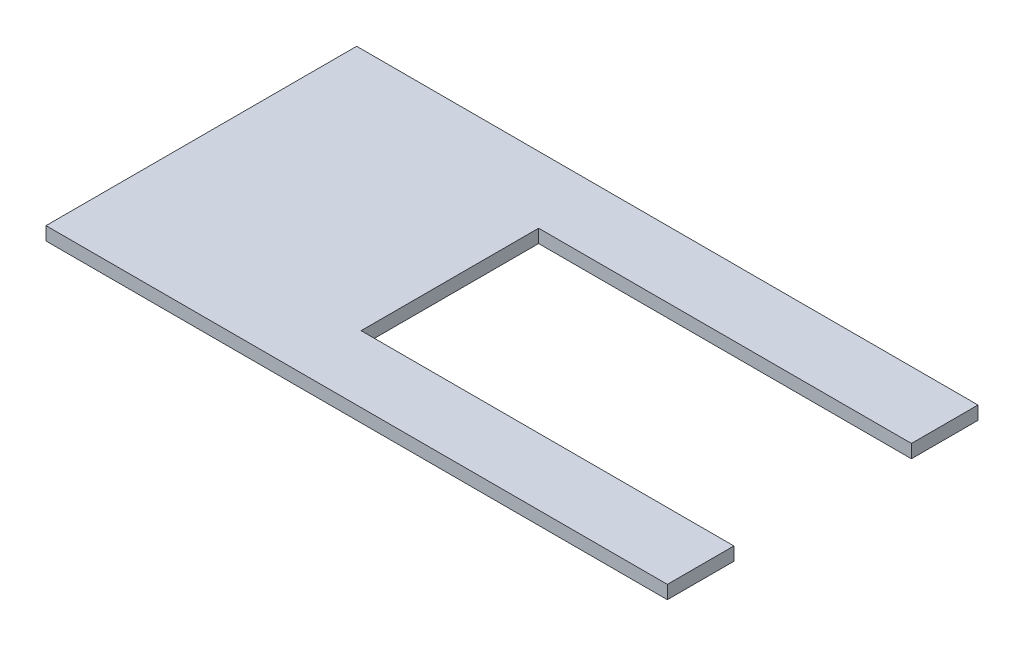
from build123d import *

# Parameters (mm, degrees)
BOSS_EXTRUDE1_DEPTH = 1.5


with BuildPart() as part:
    # Sketch1 → Boss-Extrude1 (new body)
    with BuildSketch(Plane(origin=(0, 0, 0), x_dir=(1, 0, 0), z_dir=(0, 1, 0))):
        Polygon((-35, 17.5), (-35, -17.5), (35, -17.5), (35, -10), (-7, -10), (-7, 10), (35, 10), (35, 17.5), align=None)
    extrude(amount=BOSS_EXTRUDE1_DEPTH)


solid = part.part
